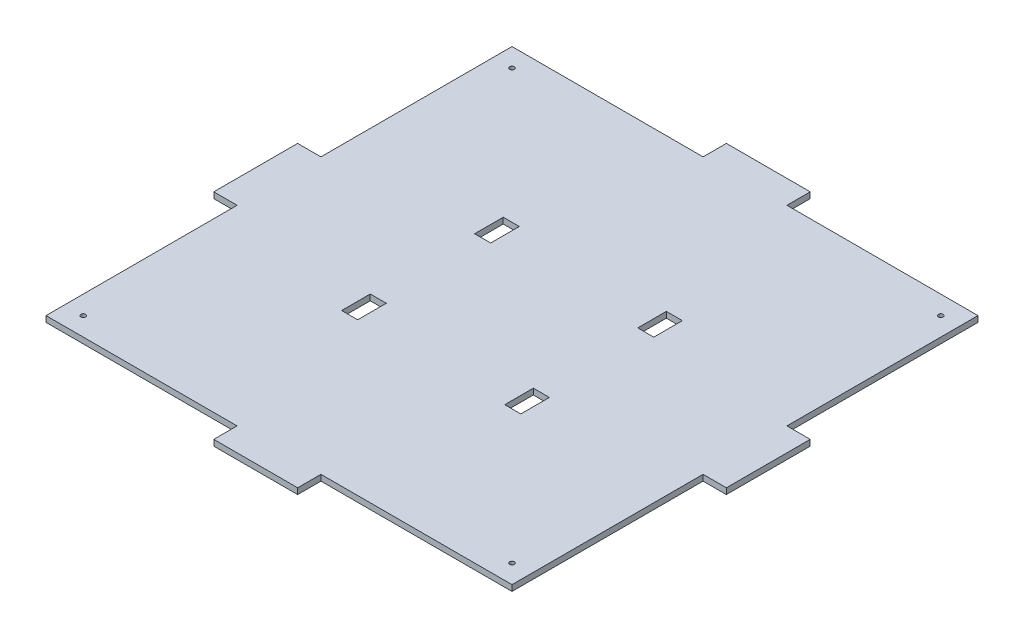
from build123d import *

# Parameters (mm, degrees)
SKETCH2_W              = 250
SKETCH2_H              = 250
BASE_DEPTH             = 3.175
SKETCH3_W              = 8.6
SKETCH3_H              = 15.35
HOLES_DEPTH            = 10
SKETCH10_W             = 45
SKETCH10_H             = 3.175
JIGSAW1_DEPTH          = 12.5
SKETCH11_W             = 45
SKETCH11_H             = 3.175
JIGSAW2_DEPTH          = 12.5
SKETCH13_W             = 45
SKETCH13_H             = 3.175
JIGSAW3_DEPTH          = 12.5
SKETCH14_W             = 45
SKETCH14_H             = 3.175
JIGSAW4_DEPTH          = 12.5
STANDOFF_HOLES_D       = 2.5
SKETCH21_R             = 1.25
STANDOFF_HOLES_2_DEPTH = 10


with BuildPart() as part:
    # Sketch2 → Base (new body)
    with BuildSketch(Plane(origin=(0, 0, 0), x_dir=(1, 0, 0), z_dir=(0, 1, 0))):
        Rectangle(SKETCH2_W, SKETCH2_H)
    extrude(amount=BASE_DEPTH)

    # Sketch3 → Holes (cut)
    with BuildSketch(Plane(origin=(0, 3.175, 0), x_dir=(1, 0, 0), z_dir=(0, 1, 0))):
        with Locations((-43.75, 35.675)):
            Rectangle(SKETCH3_W, SKETCH3_H)
        with Locations((-43.75, -35.675)):
            Rectangle(SKETCH3_W, SKETCH3_H)
        with Locations((43.75, -35.675)):
            Rectangle(SKETCH3_W, SKETCH3_H)
        with Locations((43.75, 35.675)):
            Rectangle(SKETCH3_W, SKETCH3_H)
    extrude(amount=-HOLES_DEPTH, mode=Mode.SUBTRACT)

    # Sketch10 → Jigsaw1 (add)
    with BuildSketch(Plane(origin=(0, 0, -125), x_dir=(-1, 0, 0), z_dir=(0, 0, -1))):
        with Locations((0, 1.5875)):
            Rectangle(SKETCH10_W, SKETCH10_H)
    extrude(amount=JIGSAW1_DEPTH)

    # Sketch11 → Jigsaw2 (add)
    with BuildSketch(Plane.ZY.offset(125)):
        with Locations((0, 1.5875)):
            Rectangle(SKETCH11_W, SKETCH11_H)
    extrude(amount=JIGSAW2_DEPTH)

    # Sketch13 → Jigsaw3 (add)
    with BuildSketch(Plane.XY.offset(125)):
        with Locations((0, 1.5875)):
            Rectangle(SKETCH13_W, SKETCH13_H)
    extrude(amount=JIGSAW3_DEPTH)

    # Sketch14 → Jigsaw4 (add)
    with BuildSketch(Plane(origin=(125, 0, 0), x_dir=(0, 0, -1), z_dir=(1, 0, 0))):
        with Locations((0, 1.5875)):
            Rectangle(SKETCH14_W, SKETCH14_H)
    extrude(amount=JIGSAW4_DEPTH)

    # Standoff Holes (through all)
    with Locations(Plane(origin=(-115, 3.175, -115), x_dir=(0, 0, 1), z_dir=(0, 1, 0))):
        with Locations((0, 0)):
            Hole(STANDOFF_HOLES_D / 2)

    # Sketch21 → Standoff Holes 2 (cut)
    with BuildSketch(Plane(origin=(0, 3.175, 0), x_dir=(1, 0, 0), z_dir=(0, 1, 0))):
        with Locations((115, 115)):
            Circle(SKETCH21_R)
        with Locations((115, -115)):
            Circle(SKETCH21_R)
        with Locations((-115, -115)):
            Circle(SKETCH21_R)
    extrude(amount=-STANDOFF_HOLES_2_DEPTH, mode=Mode.SUBTRACT)


solid = part.part
